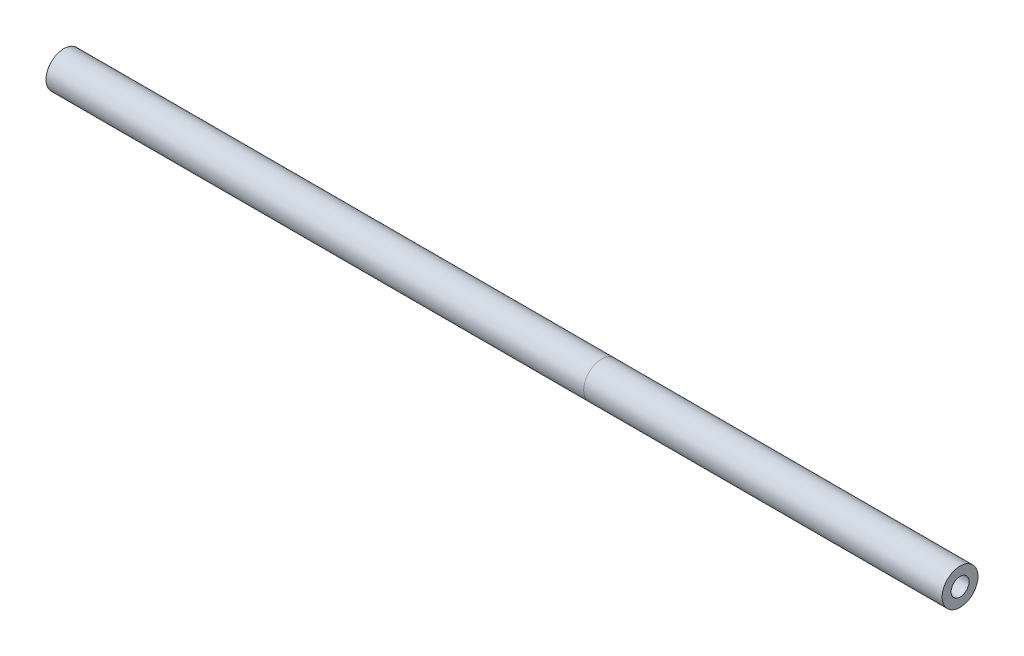
from build123d import *

# Parameters (mm, degrees)
SKETCH12_R                = 20
SKETCH12_R_2              = 10
PIPE_33_7_X_4_0_2_DEPTH   = 600
SKETCH12_ON_SEGMENT_2_R   = 20
SKETCH12_ON_SEGMENT_2_R_2 = 10
PIPE_33_7_X_4_0_2_2_DEPTH = 400


with BuildPart() as part:
    # Sketch12 → Pipe 33.7 X 4.0(2) (new body)
    with BuildSketch(Plane.YZ):
        Circle(SKETCH12_R)
        Circle(SKETCH12_R_2, mode=Mode.SUBTRACT)
    extrude(amount=PIPE_33_7_X_4_0_2_DEPTH)


with BuildPart() as body_2:
    # Sketch12 on segment 2 (carried to segment 2) → Pipe 33.7 X 4.0_2 2 (new body)
    with BuildSketch(Plane.YZ.offset(600)):
        Circle(SKETCH12_ON_SEGMENT_2_R)
        Circle(SKETCH12_ON_SEGMENT_2_R_2, mode=Mode.SUBTRACT)
    extrude(amount=PIPE_33_7_X_4_0_2_2_DEPTH)


solid = Compound([part.part, body_2.part])
